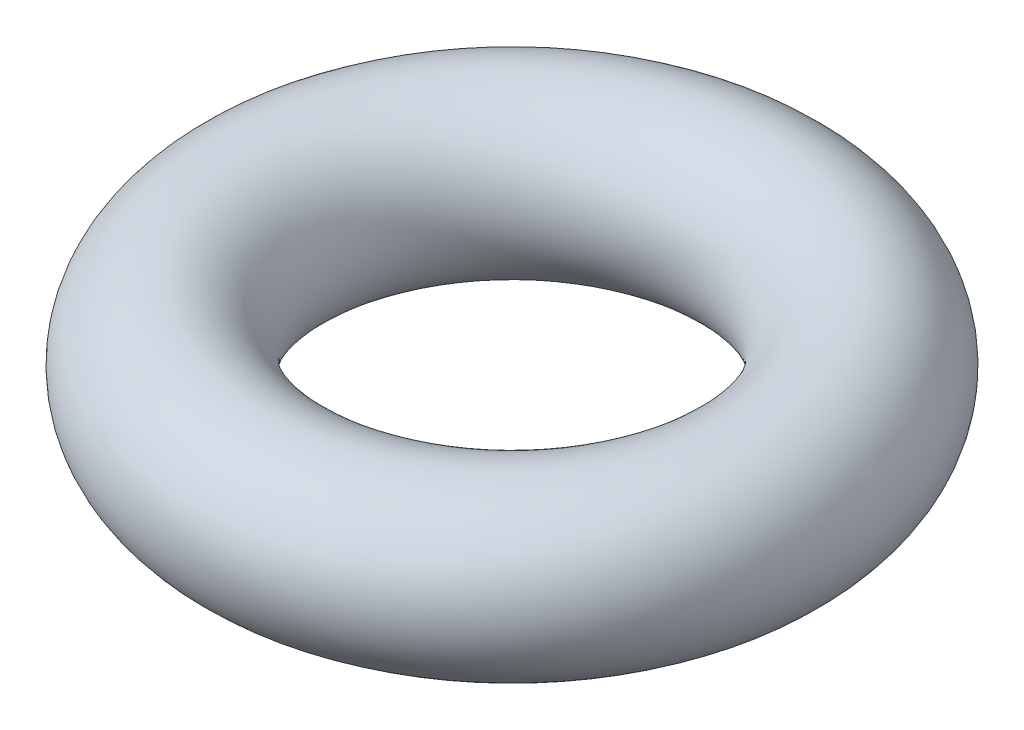
from build123d import *

# Parameters (mm, degrees)
SKETCH1_R = 25.4


with BuildPart() as part:
    # Sketch1 → Revolve1 (revolve)
    with BuildSketch(Plane.XY, mode=Mode.PRIVATE) as revolve1_sk:
        with Locations((76.2, 0)):
            Circle(SKETCH1_R)
    revolve(revolve1_sk.sketch.rotate(Axis((0, 34.961731778, 0), (0, -1, 0)), 90), axis=Axis((0, 34.961731778, 0), (0, -1, 0)))  # turned: the seam where the file's is


solid = part.part
